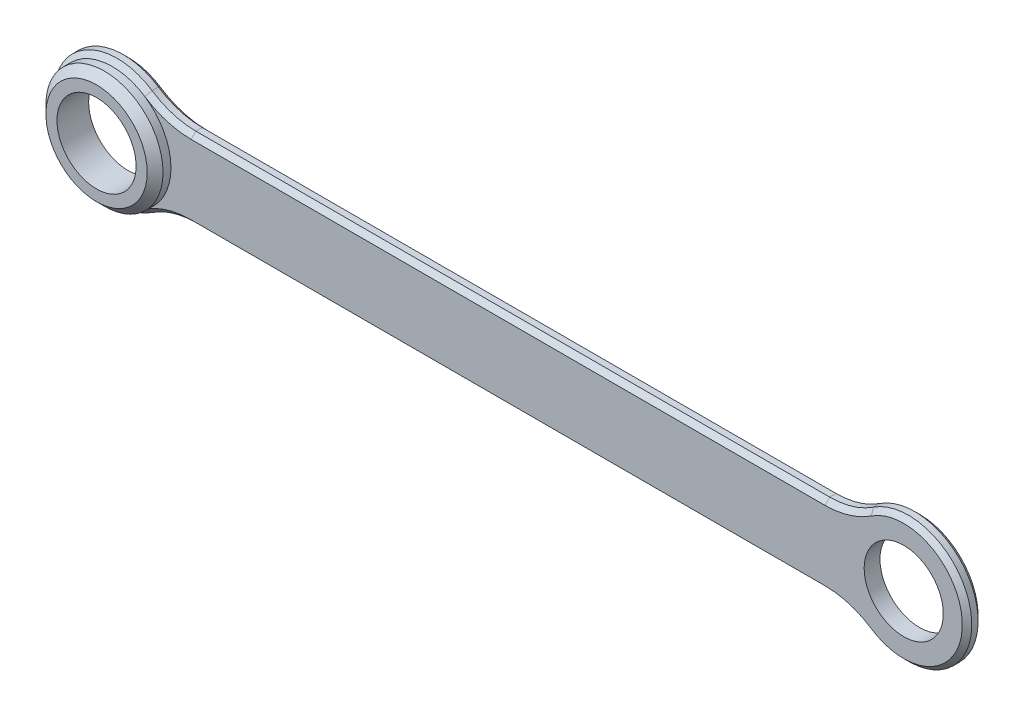
from build123d import *

# Parameters (mm, degrees)
BOSS_EXTRUDE1_DEPTH     = 0.1
FILLET1_R               = 0.5
FILLET2_R               = 0.5
CHAMFER2_SIZE           = 0.03
CHAMFER3_SIZE           = 0.03
SKETCH3_R               = 0.25
CUT_EXTRUDE1_DEPTH      = 1
CUT_EXTRUDE1_DEPTH_BACK = 1.1
SKETCH5_R               = 0.37
BOSS_EXTRUDE2_DEPTH     = 0.1
SKETCH7_R               = 0.25
CUT_EXTRUDE2_DEPTH      = 0.1
CHAMFER4_SIZE           = 0.05


with BuildPart() as part:
    # Sketch2 → Boss-Extrude1 (new body)
    with BuildSketch(Plane.XY):
        with BuildLine():
            Line((2.162109074, 0.042307692), (-2.213391126, 0.042307692))
            ThreePointArc((-2.213391126, 0.042307692), (-2.925641026, -0.207692308), (-2.213391126, -0.457692308))
            Line((-2.213391126, -0.457692308), (2.162109074, -0.457692308))
            ThreePointArc((2.162109074, -0.457692308), (2.874358974, -0.207692308), (2.162109074, 0.042307692))
        make_face()
    extrude(amount=BOSS_EXTRUDE1_DEPTH)

    # Fillet1
    fillet1_edges = [part.edges().sort_by_distance(p)[0] for p in [
        (2.162109074, 0.042307692, 0.05),
    ]]
    fillet(fillet1_edges, radius=FILLET1_R)

    # Fillet2
    fillet2_edges = [part.edges().sort_by_distance(p)[0] for p in [
        (2.162109074, -0.457692308, 0.05),
        (-2.213391126, -0.457692308, 0.05),
        (-2.213391126, 0.042307692, 0.05),
    ]]
    fillet(fillet2_edges, radius=FILLET2_R)

    # Chamfer2
    chamfer2_edges = [part.edges().sort_by_distance(p)[0] for p in [
        (2.121202823, 0.063594138, 0.1),
        (-2.925641026, -0.207692308, 0.1),
        (-0.025641026, 0.042307692, 0.1),
        (-0.025641026, -0.457692308, 0.1),
        (2.874358974, -0.207692308, 0.1),
        (-2.172484874, 0.063594138, 0.1),
        (-2.172484874, -0.478978754, 0.1),
        (2.121202823, -0.478978754, 0.1),
    ]]
    chamfer(chamfer2_edges, length=CHAMFER2_SIZE)

    # Chamfer3
    chamfer3_edges = [part.edges().sort_by_distance(p)[0] for p in [
        (2.121202823, 0.063594138, 0),
        (-2.925641026, -0.207692308, 0),
        (-0.025641026, 0.042307692, 0),
        (-0.025641026, -0.457692308, 0),
        (2.874358974, -0.207692308, 0),
        (-2.172484874, 0.063594138, 0),
        (-2.172484874, -0.478978754, 0),
        (2.121202823, -0.478978754, 0),
    ]]
    chamfer(chamfer3_edges, length=CHAMFER3_SIZE)

    # Sketch3 → Cut-Extrude1 (cut, two sides)
    with BuildSketch(Plane(origin=(0, 0, 0), x_dir=(-1, 0, 0), z_dir=(0, 0, -1))) as cut_extrude1_sk:
        with Locations((-2.474358974, -0.207692308)):
            Circle(SKETCH3_R)
        with Locations((2.525641026, -0.207692308)):
            Circle(SKETCH3_R)
    extrude(amount=CUT_EXTRUDE1_DEPTH, mode=Mode.SUBTRACT)
    extrude(cut_extrude1_sk.sketch, amount=-CUT_EXTRUDE1_DEPTH_BACK, mode=Mode.SUBTRACT)

    # Sketch5 → Boss-Extrude2 (add)
    with BuildSketch(Plane.XY.offset(0.1)):
        with Locations((-2.525641026, -0.207692308)):
            Circle(SKETCH5_R)
    extrude(amount=BOSS_EXTRUDE2_DEPTH)

    # Sketch7 → Cut-Extrude2 (cut)
    with BuildSketch(Plane(origin=(0, 0, 0.1), x_dir=(-1, 0, 0), z_dir=(0, 0, -1))):
        with Locations((2.525641026, -0.207692308)):
            Circle(SKETCH7_R)
    extrude(amount=-CUT_EXTRUDE2_DEPTH, mode=Mode.SUBTRACT)

    # Chamfer4
    chamfer4_edges = [part.edges().sort_by_distance(p)[0] for p in [
        (-2.895641026, -0.207692308, 0.2),
    ]]
    chamfer(chamfer4_edges, length=CHAMFER4_SIZE)


solid = part.part
